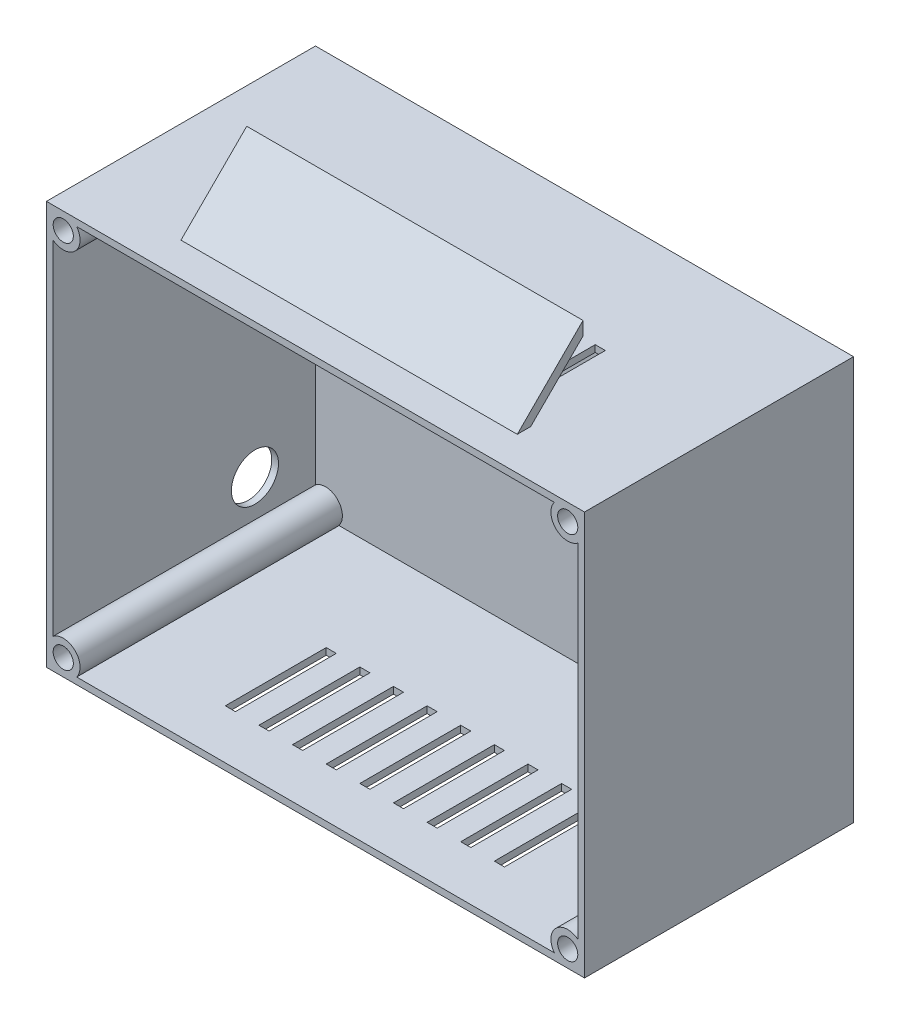
from build123d import *

# Parameters (mm, degrees)
CROQUIS1_W              = 80
CROQUIS1_H              = 60
SALIENTE_EXTRUIR1_DEPTH = 40
VACIADO1_T              = -1
CROQUIS2_R              = 2.5
CROQUIS2_R_2            = 1.5
SALIENTE_EXTRUIR2_DEPTH = 40
SALIENTE_EXTRUIR3_DEPTH = 25
CROQUIS4_W              = 1.5
CROQUIS4_H              = 15
CORTAR_EXTRUIR1_DEPTH   = 1
CROQUIS5_R              = 1.5
SALIENTE_EXTRUIR4_DEPTH = 35
CORTAR_EXTRUIR2_REACH   = 82
CROQUIS6_R              = 3.5


with BuildPart() as part:
    # Croquis1 → Saliente-Extruir1 (new body)
    with BuildSketch(Plane.XY):
        Rectangle(CROQUIS1_W, CROQUIS1_H)
    extrude(amount=SALIENTE_EXTRUIR1_DEPTH)

    # Vaciado1
    vaciado1_openings = [part.faces().sort_by_distance(p)[0] for p in [
        (0, 0, 40),
    ]]
    offset(amount=VACIADO1_T, openings=vaciado1_openings, kind=Kind.INTERSECTION)

    # Croquis2 → Saliente-Extruir2 (add)
    with BuildSketch(Plane.XY.offset(40)):
        with Locations((-37.5, 27.5)):
            Circle(CROQUIS2_R)
        with Locations((-37.5, 27.5)):
            Circle(CROQUIS2_R_2, mode=Mode.SUBTRACT)
        with Locations((37.5, 27.5)):
            Circle(CROQUIS2_R)
        with Locations((37.5, 27.5)):
            Circle(CROQUIS2_R_2, mode=Mode.SUBTRACT)
        with Locations((37.5, -27.5)):
            Circle(CROQUIS2_R)
        with Locations((37.5, -27.5)):
            Circle(CROQUIS2_R_2, mode=Mode.SUBTRACT)
        with Locations((-37.5, -27.5)):
            Circle(CROQUIS2_R)
        with Locations((-37.5, -27.5)):
            Circle(CROQUIS2_R_2, mode=Mode.SUBTRACT)
    extrude(amount=-SALIENTE_EXTRUIR2_DEPTH)

    # Croquis3 → Saliente-Extruir3 (add, symmetric)
    with BuildSketch(Plane(origin=(0, 0, 0), x_dir=(0, 0, -1), z_dir=(1, 0, 0))):
        Polygon((-35, -30), (-25.221641576, -39.778358424), (-25.221641576, -37.778358424), (-33.224472237, -29.775527763), (-35, -29.775527763), align=None)
    saliente_extruir3 = extrude(amount=SALIENTE_EXTRUIR3_DEPTH, both=True)

    # Simetría1: Saliente-Extruir3 across plane
    add(saliente_extruir3.mirror(Plane.ZX))

    # Croquis4 → Cortar-Extruir1 (cut)
    with BuildSketch(Plane(origin=(0, 30, 0), x_dir=(1, 0, 0), z_dir=(0, 1, 0))):
        with Locations((5, -25.157633817)):
            Rectangle(CROQUIS4_W, CROQUIS4_H)
        with Locations((0, -25.157633817)):
            Rectangle(CROQUIS4_W, CROQUIS4_H)
        with Locations((10, -25.157633817)):
            Rectangle(CROQUIS4_W, CROQUIS4_H)
        with Locations((15, -25.157633817)):
            Rectangle(CROQUIS4_W, CROQUIS4_H)
        with Locations((20, -25.157633817)):
            Rectangle(CROQUIS4_W, CROQUIS4_H)
        with Locations((-5, -25.157633817)):
            Rectangle(CROQUIS4_W, CROQUIS4_H)
        with Locations((-10, -25.157633817)):
            Rectangle(CROQUIS4_W, CROQUIS4_H)
        with Locations((-15, -25.157633817)):
            Rectangle(CROQUIS4_W, CROQUIS4_H)
        with Locations((-20, -25.157633817)):
            Rectangle(CROQUIS4_W, CROQUIS4_H)
    cortar_extruir1 = extrude(amount=-CORTAR_EXTRUIR1_DEPTH, mode=Mode.SUBTRACT)

    # Simetría2: Cortar-Extruir1 across plane
    add(cortar_extruir1.mirror(Plane.ZX), mode=Mode.SUBTRACT)

    # Croquis5 → Saliente-Extruir4 (add)
    with BuildSketch(Plane.XY.offset(1)):
        with Locations((37.5, -27.5)):
            Circle(CROQUIS5_R)
        with Locations((37.5, 27.5)):
            Circle(CROQUIS5_R)
        with Locations((-37.5, 27.5)):
            Circle(CROQUIS5_R)
        with Locations((-37.5, -27.5)):
            Circle(CROQUIS5_R)
    extrude(amount=SALIENTE_EXTRUIR4_DEPTH)

    # Croquis6 → Cortar-Extruir2 (cut, up to next)
    with BuildSketch(Plane.ZY.offset(40), mode=Mode.PRIVATE) as cortar_extruir2_sk1:
        with Locations((10, -20)):
            Circle(CROQUIS6_R)
    cortar_extruir2_tool1 = extrude(cortar_extruir2_sk1.sketch, amount=-CORTAR_EXTRUIR2_REACH, mode=Mode.PRIVATE) & part.part
    add(cortar_extruir2_tool1.solids().sort_by_distance((-40, -20, 10))[0], mode=Mode.SUBTRACT)


solid = part.part
